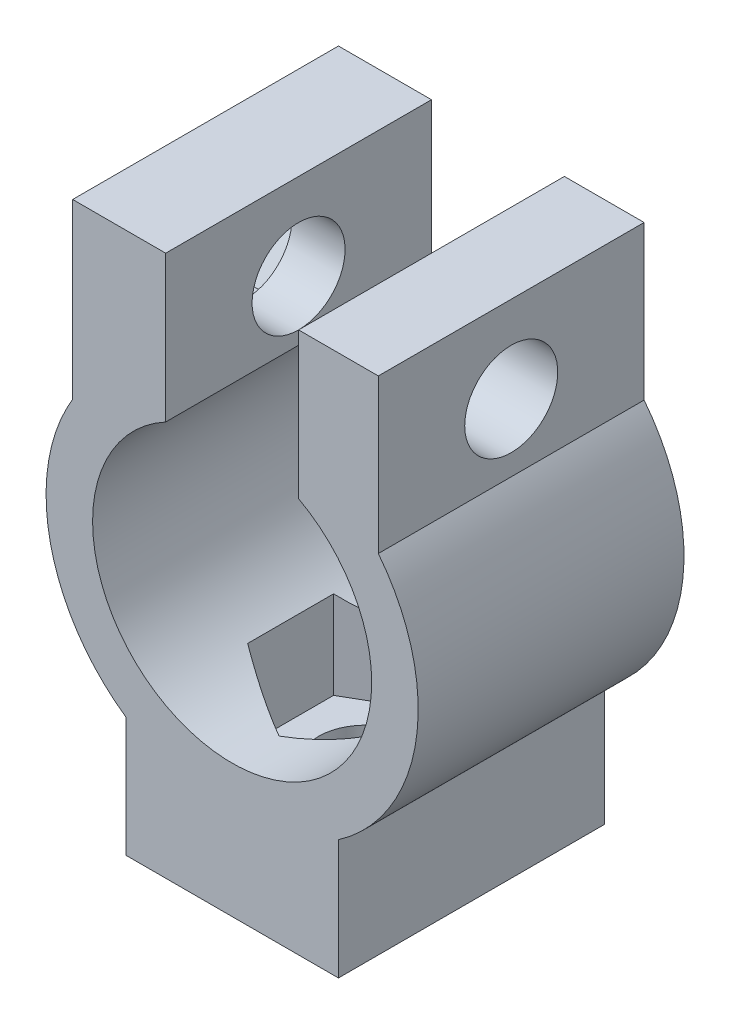
from build123d import *

# Parameters (mm, degrees)
RESSALTO_EXTRUS_O1_DEPTH   = 5
CORTE_EXTRUS_O1_START      = -10
CORTE_EXTRUS_O1_DEPTH      = 7.866546
ESBO_O4_R                  = 1.75
CORTE_EXTRUS_O2_DEPTH      = 21.366546328
ESBO_O5_R                  = 1.75
CORTE_EXTRUS_O3_DEPTH      = 2.5
CORTE_EXTRUS_O3_DEPTH_BACK = 13.5
ESBO_O6_W                  = 10
ESBO_O6_H                  = 7.25
RESSALTO_EXTRUS_O2_DEPTH   = 0.5
ESBO_O6_2_R                = 1.75
CORTE_EXTRUS_O4_DEPTH      = 1.5
CORTE_EXTRUS_O4_DEPTH_BACK = 1


with BuildPart() as part:
    # Esbo_o1 → Ressalto-extrus_o1 (new body, symmetric)
    with BuildSketch(Plane.XY):
        with BuildLine():
            Line((-4, 0), (4, 0))
            Line((4, 0), (4, 4.505437353))
            ThreePointArc((4, 4.505437353), (6.923679872, 9.219147423), (5.5, 14.580127019))
            Line((5.5, 14.580127019), (5.5, 20.366546328))
            Line((5.5, 20.366546328), (2.5, 20.366546328))
            Line((2.5, 20.366546328), (2.5, 14.866546328))
            ThreePointArc((2.5, 14.866546328), (0, 5), (-2.5, 14.866546328))
            Line((-2.5, 14.866546328), (-2.5, 20.366546328))
            Line((-2.5, 20.366546328), (-5.5, 20.366546328))
            Line((-5.5, 20.366546328), (-5.5, 14.580127019))
            ThreePointArc((-5.5, 14.580127019), (-6.923679872, 9.219147423), (-4, 4.505437353))
            Line((-4, 4.505437353), (-4, 0))
        make_face()
    extrude(amount=RESSALTO_EXTRUS_O1_DEPTH, both=True)

    # Esbo_o3 → Corte-extrus_o1 (cut)
    with BuildSketch(Plane(origin=(0, 20.366546328, 0), x_dir=(1, 0, 0), z_dir=(0, 1, 0)).offset(CORTE_EXTRUS_O1_START)):
        Polygon((0, 3.233161507), (-2.8, 1.616580754), (-2.8, -1.616580754), (0, -3.233161507), (2.8, -1.616580754), (2.8, 1.616580754), align=None)
    extrude(amount=-CORTE_EXTRUS_O1_DEPTH, mode=Mode.SUBTRACT)

    # Esbo_o4 → Corte-extrus_o2 (cut, through all)
    with BuildSketch(Plane(origin=(0, 20.366546328, 0), x_dir=(1, 0, 0), z_dir=(0, 1, 0))):
        Circle(ESBO_O4_R)
    extrude(amount=-CORTE_EXTRUS_O2_DEPTH, mode=Mode.SUBTRACT)

    # Esbo_o5 → Corte-extrus_o3 (cut, two sides)
    with BuildSketch(Plane(origin=(5.5, 0, 0), x_dir=(0, 0, -1), z_dir=(1, 0, 0))) as corte_extrus_o3_sk:
        with Locations((0, 17.116546328)):
            Circle(ESBO_O5_R)
    extrude(amount=CORTE_EXTRUS_O3_DEPTH, mode=Mode.SUBTRACT)
    extrude(corte_extrus_o3_sk.sketch, amount=-CORTE_EXTRUS_O3_DEPTH_BACK, mode=Mode.SUBTRACT)

    # Esbo_o6 → Ressalto-extrus_o2 (add)
    with BuildSketch(Plane.ZY.offset(5.5)):
        with Locations((0, 16.741546328)):
            Rectangle(ESBO_O6_W, ESBO_O6_H)
        Polygon((3.233161507, 17.116546328), (1.616580754, 19.916546328), (-1.616580754, 19.916546328), (-3.233161507, 17.116546328), (-1.616580754, 14.316546328), (1.616580754, 14.316546328), align=None, mode=Mode.SUBTRACT)
    extrude(amount=RESSALTO_EXTRUS_O2_DEPTH)

    # Esbo_o6_2 → Corte-extrus_o4 (cut, two sides)
    with BuildSketch(Plane.ZY.offset(5.5)) as corte_extrus_o4_sk:
        Polygon((-3.233161507, 17.116546328), (-1.768759136, 14.580127019), (1.768759136, 14.580127019), (3.233161507, 17.116546328), (1.616580754, 19.916546328), (-1.616580754, 19.916546328), align=None)
        with Locations((0, 17.116546328)):
            Circle(ESBO_O6_2_R, mode=Mode.SUBTRACT)
        Polygon((1.768759136, 14.580127019), (-1.768759136, 14.580127019), (-1.616580754, 14.316546328), (1.616580754, 14.316546328), align=None)
    extrude(amount=CORTE_EXTRUS_O4_DEPTH, mode=Mode.SUBTRACT)
    extrude(corte_extrus_o4_sk.sketch, amount=-CORTE_EXTRUS_O4_DEPTH_BACK, mode=Mode.SUBTRACT)


solid = part.part
